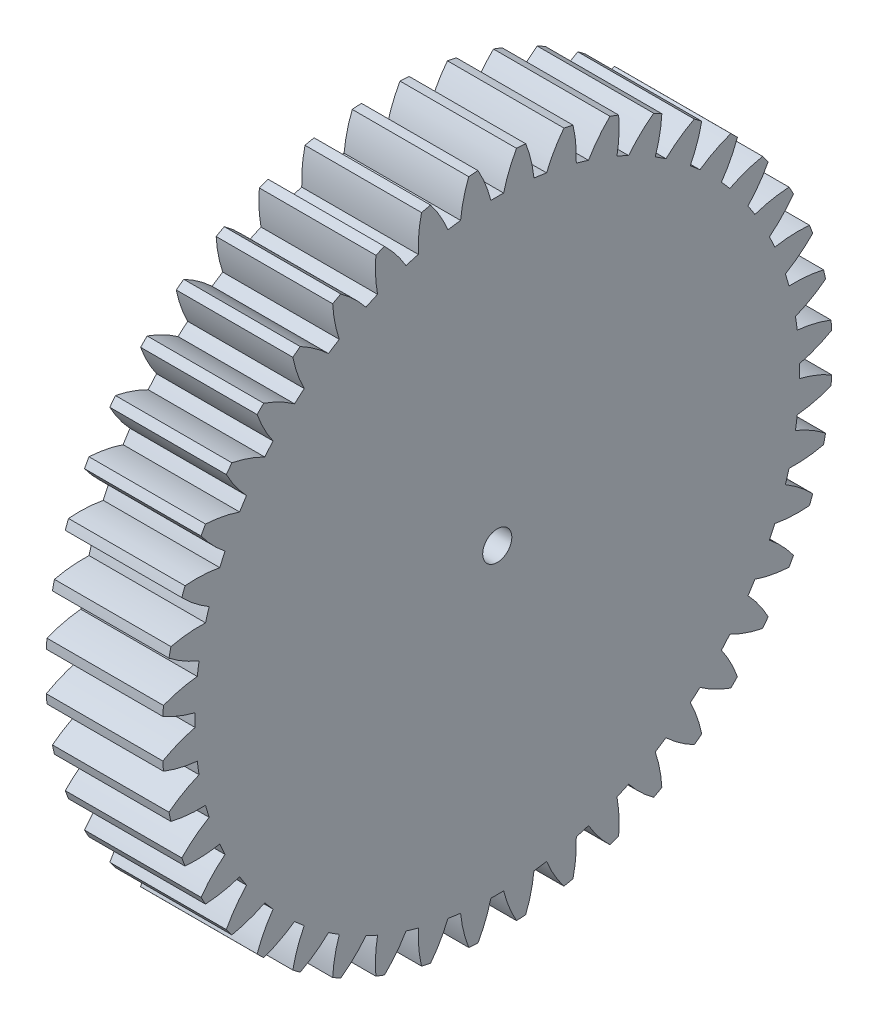
from build123d import *

# Parameters (mm, degrees)
BASPROSKE_W     = 20
BASPROSKE_H     = 57.5
TOOTHCUT_DEPTH  = 84.740671122
TEETHCUTS_COUNT = 44
TEETHCUTS_ANGLE = 351.818181818
BORSKE_R        = 2.5
BORE_DEPTH      = 50.0000508


with BuildPart() as part:
    # BasProSke → Base-Revolve (revolve)
    with BuildSketch(Plane(origin=(0, 0, 0), x_dir=(1, 0, 0), z_dir=(0, 1, 0)), mode=Mode.PRIVATE) as base_revolve_sk:
        with Locations((10, 28.75)):
            Rectangle(BASPROSKE_W, BASPROSKE_H)
    revolve(base_revolve_sk.sketch.rotate(Axis((-10, 0, 0), (1, 0, 0)), 180), axis=Axis((-10, 0, 0), (1, 0, 0)))

    # TooCutSke → ToothCut (cut, through all)
    with BuildSketch(Plane(origin=(0, 0, 0), x_dir=(0, 0, -1), z_dir=(1, 0, 0))):
        with BuildLine():
            ThreePointArc((1.096427316, 51.862411467), (0, 51.874), (-1.096427316, 51.862411467))
            ThreePointArc((-1.096427316, 51.862411467), (-2.018853505, 54.722077315), (-3.322337066, 57.429380299))
            ThreePointArc((-3.322337066, 57.429380299), (0, 57.5254), (3.322337066, 57.429380299))
            ThreePointArc((3.322337066, 57.429380299), (2.018853505, 54.722077315), (1.096427316, 51.862411467))
        make_face()
    toothcut = extrude(amount=TOOTHCUT_DEPTH, mode=Mode.SUBTRACT)

    # TeethCuts: ToothCut ×44 about axis
    teethcuts_axis = Axis((-10, 0, 0), (1, 0, 0))
    for i in range(1, TEETHCUTS_COUNT):
        add(toothcut.rotate(teethcuts_axis, i * TEETHCUTS_ANGLE / (TEETHCUTS_COUNT - 1)), mode=Mode.SUBTRACT)

    # BorSke → Bore (cut, symmetric)
    with BuildSketch(Plane(origin=(0, 0, 0), x_dir=(0, 0, -1), z_dir=(1, 0, 0))):
        with Locations(Location((0, 0, 0), (0, 0, 180))):
            Circle(BORSKE_R)
    extrude(amount=BORE_DEPTH, both=True, mode=Mode.SUBTRACT)


solid = part.part
